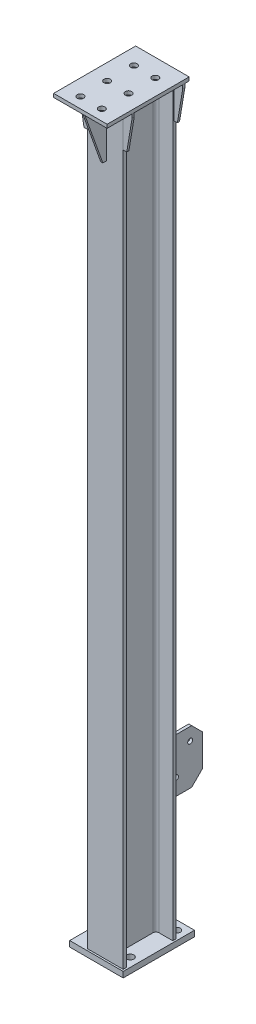
from build123d import *

# Parameters (mm, degrees)
H_HM150_100_1_DEPTH = 2090
SKETCH_12_W         = 150
SKETCH_12_H         = 200
EXTRUDE_1_DEPTH     = 16
SKETCH_13_W         = 230
SKETCH_13_H         = 150
EXTRUDE_2_DEPTH     = 10
SKETCH_15_R         = 9
CUT_EXTRUDE_2_DEPTH = 10
EXTRUDE_3_DEPTH     = 6
EXTRUDE_3_2_DEPTH   = 6
EXTRUDE_4_DEPTH     = 6
EXTRUDE_4_2_DEPTH   = 6
EXTRUDE_5_DEPTH     = 6
SKETCH_19_W         = 8
SKETCH_19_H         = 150
EXTRUDE_6_DEPTH     = 120
SKETCH_23_R         = 10
CUT_EXTRUDE_5_DEPTH = 16
CHAMFER_1_SIZE      = 30
SKETCH_20_R         = 7
CUT_EXTRUDE_3_DEPTH = 120


with BuildPart() as part:
    # 草图11 → H型钢 HM150×100(1) (new body)
    with BuildSketch(Plane(origin=(-50, -1518.192662688, 7133.668163116), x_dir=(1, 0, 0), z_dir=(0, -1, 0))):
        with BuildLine():
            Line((-50, -74), (50, -74))
            Line((50, -74), (50, -65))
            Line((50, -65), (11, -65))
            ThreePointArc((11, -65), (5.343145751, -62.656854249), (3, -57))
            Line((3, -57), (3, 57))
            ThreePointArc((3, 57), (5.343145751, 62.656854249), (11, 65))
            Line((11, 65), (50, 65))
            Line((50, 65), (50, 74))
            Line((50, 74), (-50, 74))
            Line((-50, 74), (-50, 65))
            Line((-50, 65), (-11, 65))
            ThreePointArc((-11, 65), (-5.343145751, 62.656854249), (-3, 57))
            Line((-3, 57), (-3, -57))
            ThreePointArc((-3, -57), (-5.343145751, -62.656854249), (-11, -65))
            Line((-11, -65), (-50, -65))
            Line((-50, -65), (-50, -74))
        make_face()
    extrude(amount=H_HM150_100_1_DEPTH)


with BuildPart() as body_2:
    # 草图12 → 凸台-拉伸1 (new body)
    with BuildSketch(Plane.XZ.offset(3608.192662688)):
        with Locations((-70, 7112.668163116)):
            Rectangle(SKETCH_12_W, SKETCH_12_H)
    extrude(amount=EXTRUDE_1_DEPTH)

    # 草图23 → 切除-拉伸5 (cut)
    with BuildSketch(Plane(origin=(0, -3608.192662688, 0), x_dir=(1, 0, 0), z_dir=(0, 1, 0))):
        with Locations(Location((-120, -7037.668163116, 0), (0, 0, 270))):
            Circle(SKETCH_23_R)
        with Locations(Location((-120, -7167.668163116, 0), (0, 0, 270))):
            Circle(SKETCH_23_R)
        with Locations(Location((-20, -7037.668163116, 0), (0, 0, 270))):
            Circle(SKETCH_23_R)
        with Locations(Location((-20, -7167.668163116, 0), (0, 0, 270))):
            Circle(SKETCH_23_R)
    extrude(amount=-CUT_EXTRUDE_5_DEPTH, mode=Mode.SUBTRACT)


with BuildPart() as body_3:
    # 草图13 → 凸台-拉伸2 (new body)
    with BuildSketch(Plane(origin=(-1618.192662688, -1518.192662688, 0), x_dir=(0, 0, 1), z_dir=(0, -1, 0))):
        with Locations((7162.668163116, -1568.192662688)):
            Rectangle(SKETCH_13_W, SKETCH_13_H)
    extrude(amount=-EXTRUDE_2_DEPTH)

    # 草图15 → 切除-拉伸2 (cut)
    with BuildSketch(Plane(origin=(1383.192662688, -1508.192662688, 0), x_dir=(1, 0, 0), z_dir=(0, 1, 0))):
        with Locations(Location((-1403.192662688, -7247.668163116, 0), (0, 0, 270))):
            Circle(SKETCH_15_R)
        with Locations(Location((-1463.192662688, -7247.668163116, 0), (0, 0, 270))):
            Circle(SKETCH_15_R)
        with Locations(Location((-1463.192662688, -7172.668163116, 0), (0, 0, 270))):
            Circle(SKETCH_15_R)
        with Locations(Location((-1403.192662688, -7172.668163116, 0), (0, 0, 270))):
            Circle(SKETCH_15_R)
        with Locations(Location((-1403.192662688, -7097.668163116, 0), (0, 0, 270))):
            Circle(SKETCH_15_R)
        with Locations(Location((-1463.192662688, -7097.668163116, 0), (0, 0, 270))):
            Circle(SKETCH_15_R)
    extrude(amount=-CUT_EXTRUDE_2_DEPTH, mode=Mode.SUBTRACT)


with BuildPart() as body_4:
    # 草图16 → 凸台-拉伸3 (new body)
    with BuildSketch(Plane.XY.offset(7207.668163116)):
        Polygon((-125, -1518.192662688), (-125, -1528.192662688), (-110, -1618.192662688), (-100, -1618.192662688), (-100, -1518.192662688), align=None)
    extrude(amount=-EXTRUDE_3_DEPTH)


with BuildPart() as body_5:
    # 草图16 → Extrude 3 2 (new body)
    with BuildSketch(Plane.XY.offset(7207.668163116)):
        Polygon((25, -1518.192662688), (0, -1518.192662688), (0, -1618.192662688), (10, -1618.192662688), (25, -1528.192662688), align=None)
    extrude(amount=-EXTRUDE_3_2_DEPTH)


with BuildPart() as body_6:
    # 草图17 → 凸台-拉伸4 (new body)
    with BuildSketch(Plane(origin=(0, 0, 7059.668163116), x_dir=(-1, 0, 0), z_dir=(0, 0, -1))):
        Polygon((-25, -1518.192662688), (-25, -1528.192662688), (-10, -1618.192662688), (0, -1618.192662688), (0, -1518.192662688), align=None)
    extrude(amount=-EXTRUDE_4_DEPTH)


with BuildPart() as body_7:
    # 草图17 → Extrude 4 2 (new body)
    with BuildSketch(Plane(origin=(0, 0, 7059.668163116), x_dir=(-1, 0, 0), z_dir=(0, 0, -1))):
        Polygon((125, -1518.192662688), (100, -1518.192662688), (100, -1618.192662688), (110, -1618.192662688), (125, -1528.192662688), align=None)
    extrude(amount=-EXTRUDE_4_2_DEPTH)


with BuildPart() as body_8:
    # 草图18 → 凸台-拉伸5 (new body)
    with BuildSketch(Plane(origin=(-47, 0, 0), x_dir=(0, 0, -1), z_dir=(1, 0, 0))):
        Polygon((-7207.668163116, -1518.192662688), (-7267.668163116, -1518.192662688), (-7267.668163116, -1528.192662688), (-7217.668163116, -1668.192662688), (-7207.668163116, -1668.192662688), align=None)
    extrude(amount=-EXTRUDE_5_DEPTH)


with BuildPart() as body_9:
    # 草图19 → 凸台-拉伸6 (new body)
    with BuildSketch(Plane(origin=(0, 0, 7059.668163116), x_dir=(-1, 0, 0), z_dir=(0, 0, -1))):
        with Locations((50, -3233.192662688)):
            Rectangle(SKETCH_19_W, SKETCH_19_H)
    extrude(amount=EXTRUDE_6_DEPTH)

    # 倒角1
    chamfer_1_edges = [body_9.edges().sort_by_distance(p)[0] for p in [
        (-50, -3158.192662688, 6939.668163116),
        (-50, -3308.192662688, 6939.668163116),
    ]]
    chamfer(chamfer_1_edges, length=CHAMFER_1_SIZE)

    # 草图20 → 切除-拉伸3 (cut)
    with BuildSketch(Plane(origin=(-46, 0, 0), x_dir=(0, 0, -1), z_dir=(1, 0, 0))):
        with Locations(Location((-7013.687401002, -3263.192662688, 0), (0, 0, 90))):
            Circle(SKETCH_20_R)
        with Locations(Location((-6973.687401002, -3193.910630386, 0), (0, 0, 90))):
            Circle(SKETCH_20_R)
    extrude(amount=-CUT_EXTRUDE_3_DEPTH, mode=Mode.SUBTRACT)


solid = Compound([part.part, body_2.part, body_3.part, body_4.part, body_5.part, body_6.part, body_7.part, body_8.part, body_9.part])
